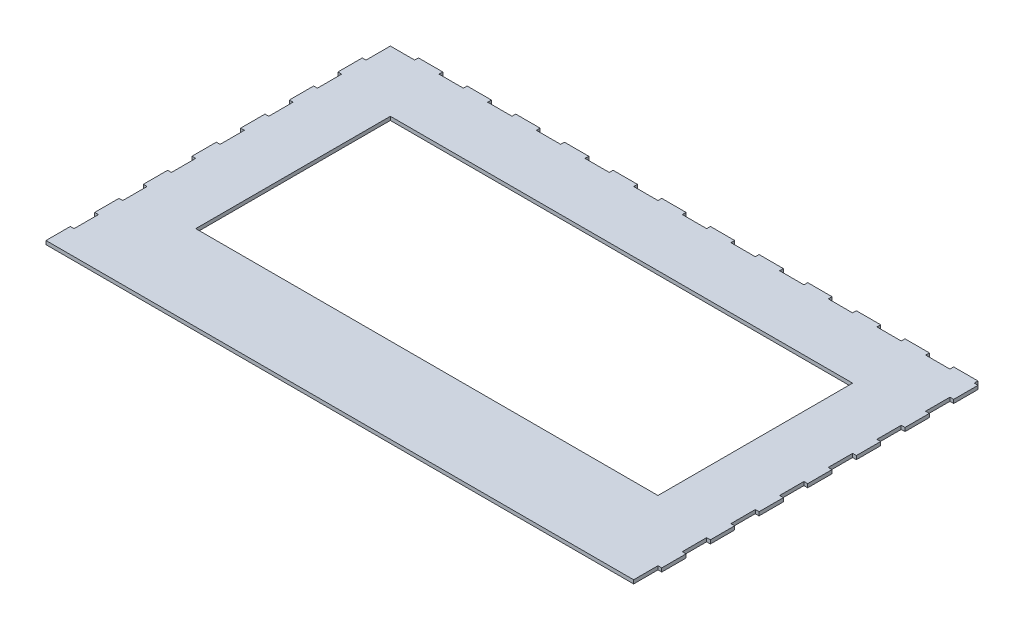
from build123d import *

# Parameters (mm, degrees)
SALIENTE_EXTRUIR1_DEPTH = 3
CROQUIS2_W              = 380
CROQUIS2_H              = 160
CORTAR_EXTRUIR1_DEPTH   = 3


with BuildPart() as part:
    # Croquis1 → Saliente-Extruir1 (new body)
    with BuildSketch(Plane(origin=(0, 0, 0), x_dir=(1, 0, 0), z_dir=(0, 1, 0))):
        Polygon((480, 280), (480, 283.1), (460, 283.1), (460, 280), (440, 280), (440, 283.1), (420, 283.1), (420, 280), (400, 280), (400, 283.1), (380, 283.1), (380, 280), (360, 280), (360, 283.1), (340, 283.1), (340, 280), (320, 280), (320, 283.1), (300, 283.1), (300, 280), (280, 280), (280, 283.1), (260, 283.1), (260, 280), (240, 280), (240, 283.1), (220, 283.1), (220, 280), (200, 280), (200, 283.1), (180, 283.1), (180, 280), (160, 280), (160, 283.1), (140, 283.1), (140, 280), (120, 280), (120, 283.1), (100, 283.1), (100, 280), (80, 280), (80, 283.1), (60, 283.1), (60, 280), (40, 280), (40, 283.1), (20, 283.1), (20, 280), (0, 280), (0, 260), (-3.1, 260), (-3.1, 240), (0, 240), (0, 220), (-3.1, 220), (-3.1, 200), (0, 200), (0, 180), (-3.1, 180), (-3.1, 160), (0, 160), (0, 140), (-3.1, 140), (-3.1, 120), (0, 120), (0, 100), (-3.1, 100), (-3.1, 80), (0, 80), (0, 60), (-3.1, 60), (-3.1, 40), (0, 40), (0, 20), (-3.1, 20), (-3.1, 0), (0, 0), (480, 0), (480, 20), (483.1, 20), (483.1, 40), (480, 40), (480, 60), (483.1, 60), (483.1, 80), (480, 80), (480, 100), (483.1, 100), (483.1, 120), (480, 120), (480, 140), (483.1, 140), (483.1, 160), (480, 160), (480, 180), (483.1, 180), (483.1, 200), (480, 200), (480, 220), (483.1, 220), (483.1, 240), (480, 240), (480, 260), (483.1, 260), (483.1, 280), align=None)
    extrude(amount=SALIENTE_EXTRUIR1_DEPTH)

    # Croquis2 → Cortar-Extruir1 (cut)
    with BuildSketch(Plane(origin=(0, 3, 0), x_dir=(1, 0, 0), z_dir=(0, 1, 0))):
        with Locations((240, 150)):
            Rectangle(CROQUIS2_W, CROQUIS2_H)
    extrude(amount=-CORTAR_EXTRUIR1_DEPTH, mode=Mode.SUBTRACT)


solid = part.part
